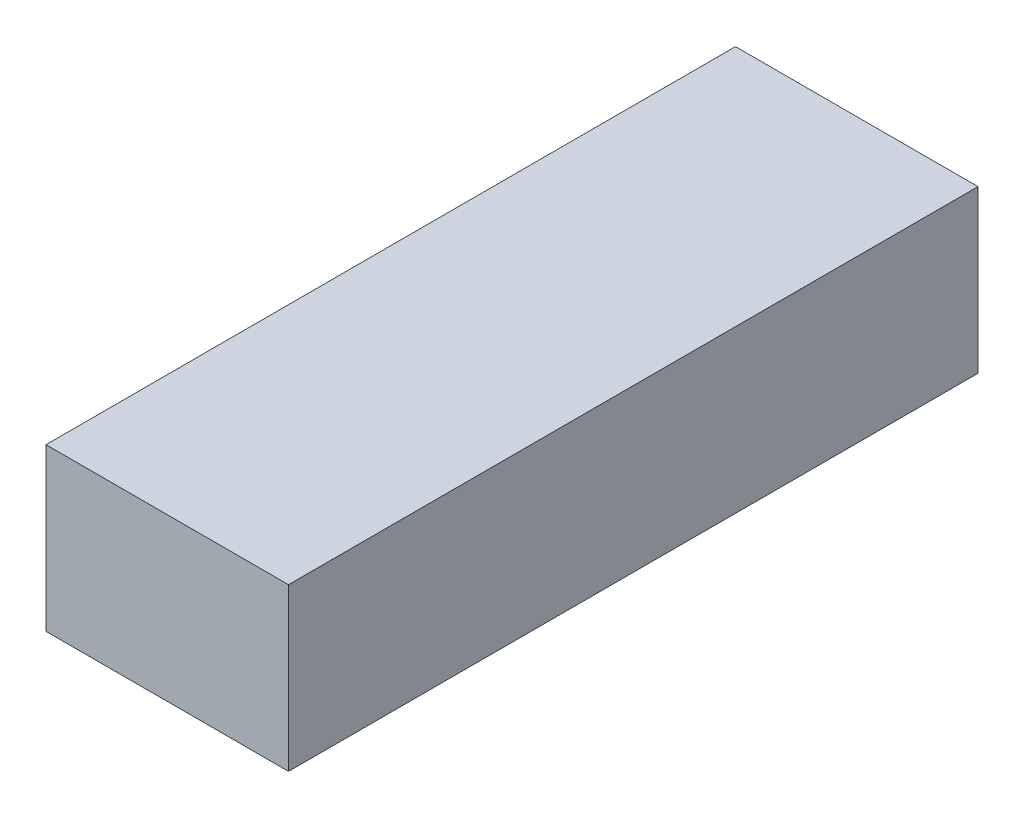
from build123d import *

# Parameters (mm, degrees)
SKETCH1_W           = 51
SKETCH1_H           = 34
BOSS_EXTRUDE1_DEPTH = 145


with BuildPart() as part:
    # Sketch1 → Boss-Extrude1 (new body)
    with BuildSketch(Plane.XY):
        Rectangle(SKETCH1_W, SKETCH1_H)
    extrude(amount=BOSS_EXTRUDE1_DEPTH)


solid = part.part
